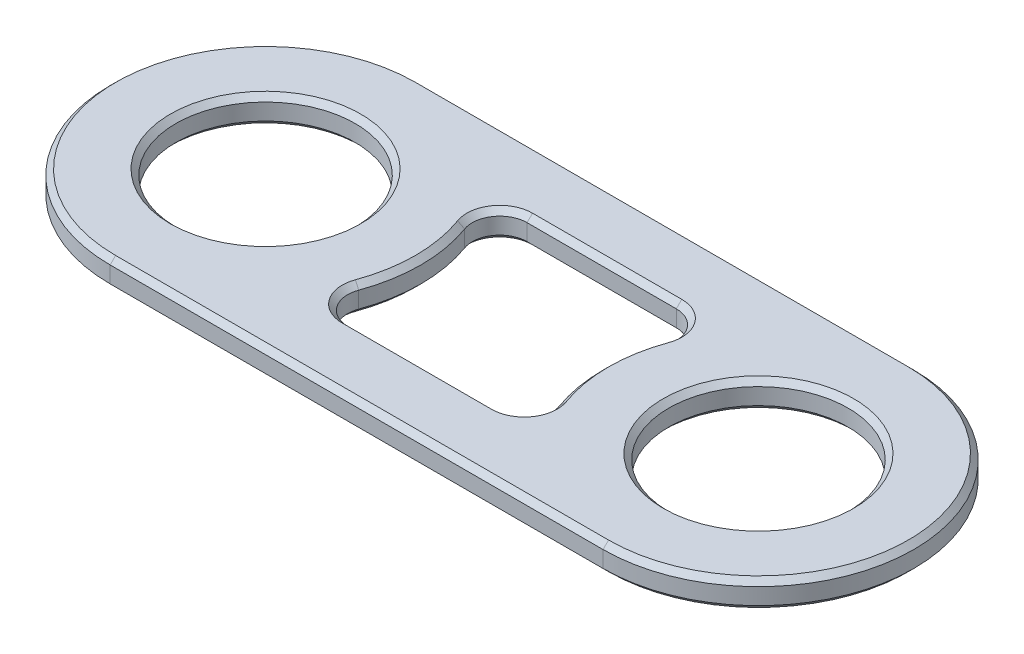
from build123d import *

# Parameters (mm, degrees)
SKETCH1_R           = 3.275
BOSS_EXTRUDE1_DEPTH = 1
CHAMFER1_SIZE       = 0.2


with BuildPart() as part:
    # Sketch1 → Boss-Extrude1 (new body)
    with BuildSketch(Plane(origin=(0, 0, 0), x_dir=(1, 0, 0), z_dir=(0, 1, 0))):
        with BuildLine():
            Line((-9, 5.675), (9, 5.675))
            ThreePointArc((9, 5.675), (14.675, 0), (9, -5.675))
            Line((9, -5.675), (-9, -5.675))
            ThreePointArc((-9, -5.675), (-14.675, 0), (-9, 5.675))
        make_face()
        with Locations((-9, 0)):
            Circle(SKETCH1_R, mode=Mode.SUBTRACT)
        with Locations((9, 0)):
            Circle(SKETCH1_R, mode=Mode.SUBTRACT)
        with BuildLine():
            Line((-2.724651404, 3.275), (2.724651404, 3.275))
            ThreePointArc((2.724651404, 3.275), (3.543438303, 2.849097566), (3.664778535, 1.93417603))
            ThreePointArc((3.664778535, 1.93417603), (3.325, 0), (3.664778535, -1.93417603))
            ThreePointArc((3.664778535, -1.93417603), (3.543438303, -2.849097566), (2.724651404, -3.275))
            Line((2.724651404, -3.275), (-2.724651404, -3.275))
            ThreePointArc((-2.724651404, -3.275), (-3.543438303, -2.849097566), (-3.664778535, -1.93417603))
            ThreePointArc((-3.664778535, -1.93417603), (-3.325, 0), (-3.664778535, 1.93417603))
            ThreePointArc((-3.664778535, 1.93417603), (-3.543438303, 2.849097566), (-2.724651404, 3.275))
        make_face(mode=Mode.SUBTRACT)
    extrude(amount=BOSS_EXTRUDE1_DEPTH)

    # Chamfer1
    chamfer1_edges = [part.edges().sort_by_distance(p)[0] for p in [
        (-12.275, 0, 0),
        (-12.275, 1, 0),
        (14.675, 1, 0),
        (0, 1, -5.675),
        (3.543438303, 0, -2.849097566),
        (0, 0, -3.275),
        (-3.543438303, 0, -2.849097566),
        (-3.325, 0, 0),
        (-3.543438303, 0, 2.849097566),
        (0, 0, 3.275),
        (3.543438303, 0, 2.849097566),
        (3.325, 0, 0),
        (3.543438303, 1, -2.849097566),
        (0, 1, -3.275),
        (-3.543438303, 1, -2.849097566),
        (-3.325, 1, 0),
        (-3.543438303, 1, 2.849097566),
        (0, 1, 3.275),
        (3.543438303, 1, 2.849097566),
        (3.325, 1, 0),
        (5.725, 0, 0),
        (5.725, 1, 0),
        (-14.675, 1, 0),
        (0, 0, -5.675),
        (14.675, 0, 0),
        (0, 0, 5.675),
        (-14.675, 0, 0),
        (0, 1, 5.675),
    ]]
    chamfer(chamfer1_edges, length=CHAMFER1_SIZE)


solid = part.part
